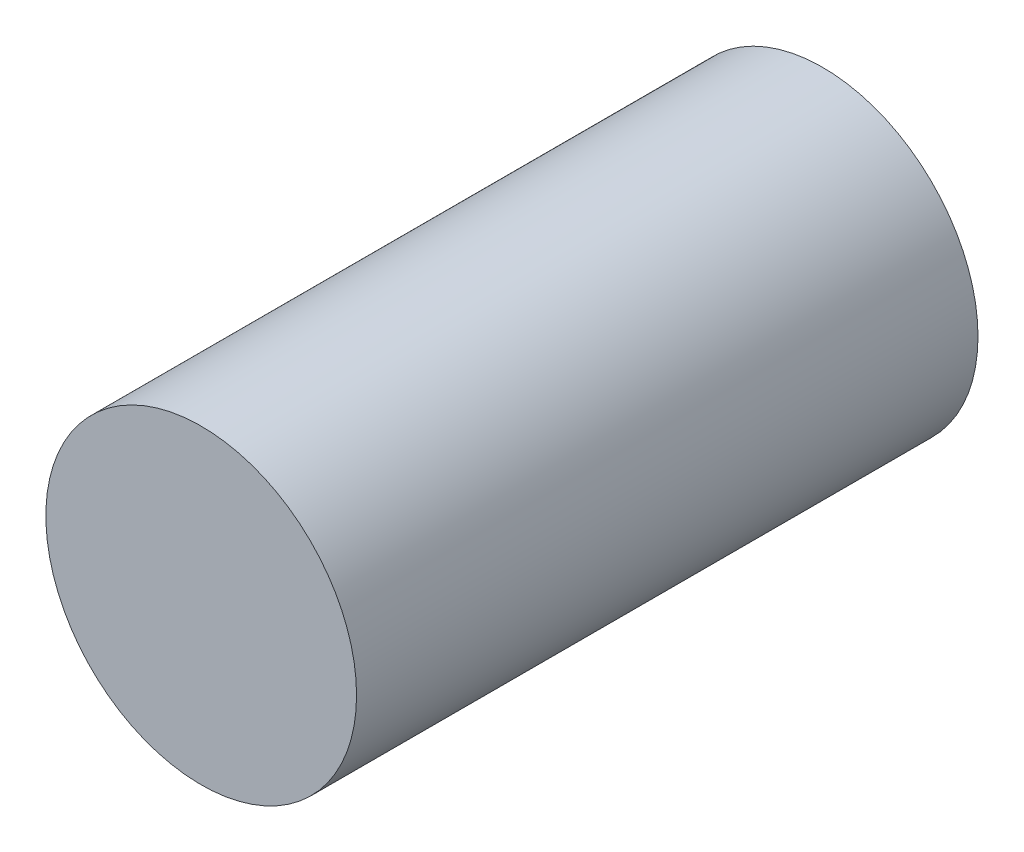
from build123d import *

# Parameters (mm, degrees)
SKETCH1_R           = 5
BOSS_EXTRUDE1_DEPTH = 10


with BuildPart() as part:
    # Sketch1 → Boss-Extrude1 (new body, symmetric)
    with BuildSketch(Plane.XY):
        Circle(SKETCH1_R)
    extrude(amount=BOSS_EXTRUDE1_DEPTH, both=True)


solid = part.part
